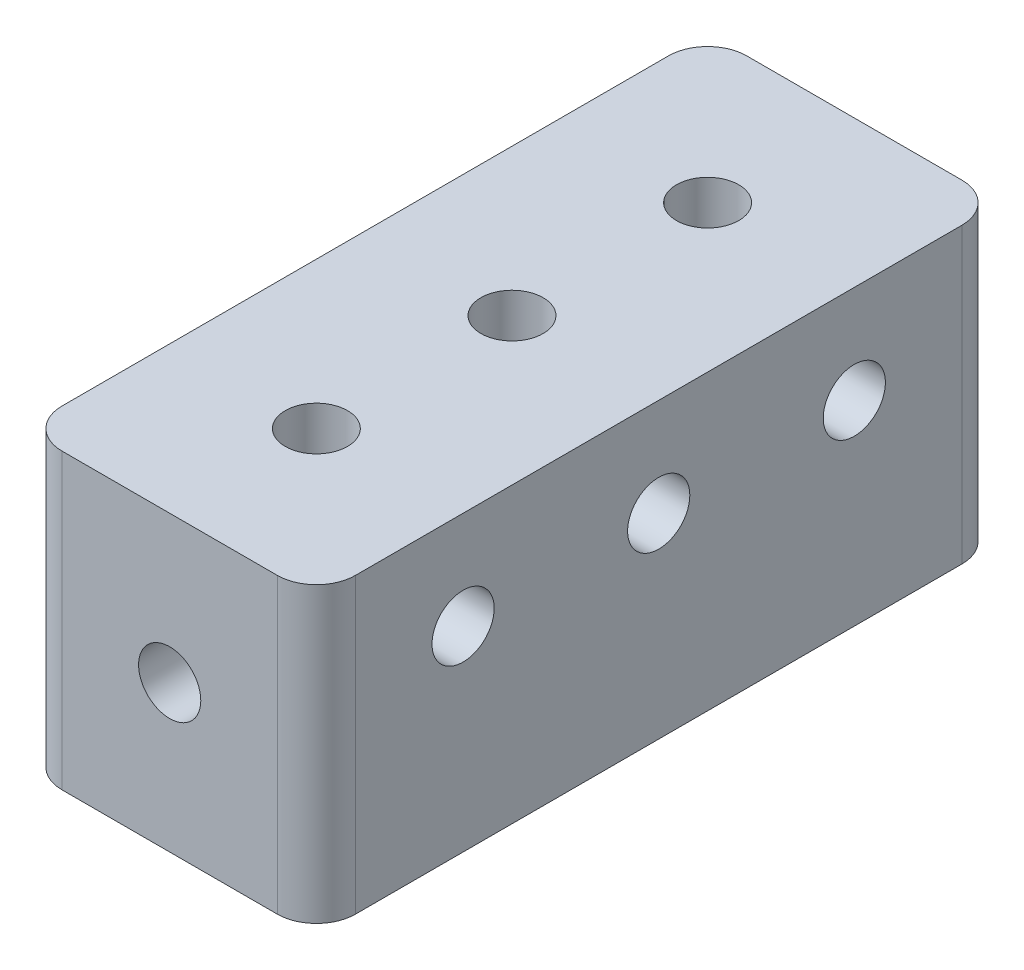
from build123d import *

# Parameters (mm, degrees)
SKETCH1_W           = 19.05
SKETCH1_H           = 44.45
BOSS_EXTRUDE1_DEPTH = 9.525
SKETCH2_R           = 2.0193
CUT_EXTRUDE1_DEPTH  = 9.525
SKETCH3_R           = 2.0193
CUT_EXTRUDE2_DEPTH  = 9.525
SKETCH4_R           = 2.0193
CUT_EXTRUDE3_DEPTH  = 6.35
SKETCH5_R           = 2.0193
CUT_EXTRUDE4_DEPTH  = 6.35
SKETCH6_R           = 2.0193
CUT_EXTRUDE5_DEPTH  = 6.35
FILLET1_R           = 2.54


with BuildPart() as part:
    # Sketch1 → Boss-Extrude1 (new body, symmetric)
    with BuildSketch(Plane(origin=(0, 0, 0), x_dir=(1, 0, 0), z_dir=(0, 1, 0))):
        Rectangle(SKETCH1_W, SKETCH1_H)
    extrude(amount=BOSS_EXTRUDE1_DEPTH, both=True)

    # Sketch2 → Cut-Extrude1 (cut)
    with BuildSketch(Plane.XY.offset(22.225)):
        Circle(SKETCH2_R)
    extrude(amount=-CUT_EXTRUDE1_DEPTH, mode=Mode.SUBTRACT)

    # Sketch3 → Cut-Extrude2 (cut)
    with BuildSketch(Plane(origin=(0, 0, -22.225), x_dir=(-1, 0, 0), z_dir=(0, 0, -1))):
        Circle(SKETCH3_R)
    extrude(amount=-CUT_EXTRUDE2_DEPTH, mode=Mode.SUBTRACT)

    # Sketch4 → Cut-Extrude3 (cut)
    with BuildSketch(Plane(origin=(9.525, 0, 0), x_dir=(0, 0, -1), z_dir=(1, 0, 0))):
        with Locations((-12.7, 3.175)):
            Circle(SKETCH4_R)
        with Locations((12.7, 3.175)):
            Circle(SKETCH4_R)
        with Locations((0, 3.175)):
            Circle(SKETCH4_R)
    extrude(amount=-CUT_EXTRUDE3_DEPTH, mode=Mode.SUBTRACT)

    # Sketch5 → Cut-Extrude4 (cut)
    with BuildSketch(Plane.ZY.offset(9.525)):
        with Locations((-12.7, 3.175)):
            Circle(SKETCH5_R)
        with Locations((0, 3.175)):
            Circle(SKETCH5_R)
        with Locations((12.7, 3.175)):
            Circle(SKETCH5_R)
    extrude(amount=-CUT_EXTRUDE4_DEPTH, mode=Mode.SUBTRACT)

    # Sketch6 → Cut-Extrude5 (cut)
    with BuildSketch(Plane(origin=(0, 9.525, 0), x_dir=(1, 0, 0), z_dir=(0, 1, 0))):
        with Locations((0, 12.7)):
            Circle(SKETCH6_R)
        Circle(SKETCH6_R)
        with Locations((0, -12.7)):
            Circle(SKETCH6_R)
    extrude(amount=-CUT_EXTRUDE5_DEPTH, mode=Mode.SUBTRACT)

    # Fillet1
    fillet1_edges = [part.edges().sort_by_distance(p)[0] for p in [
        (9.525, 0, 22.225),
        (-9.525, 0, 22.225),
        (-9.525, 0, -22.225),
        (9.525, 0, -22.225),
    ]]
    fillet(fillet1_edges, radius=FILLET1_R)


solid = part.part
